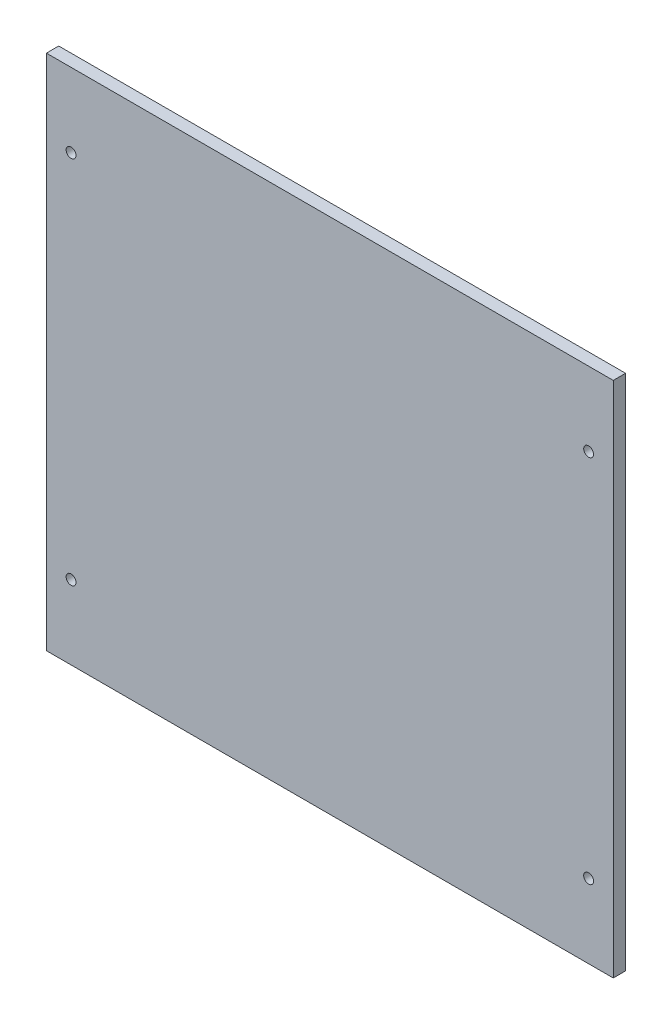
from build123d import *

# Parameters (mm, degrees)
SKETCH1_W           = 230
SKETCH1_H           = 210
BOSS_EXTRUDE1_DEPTH = 5
SKETCH2_R           = 2
CUT_EXTRUDE1_DEPTH  = 25


with BuildPart() as part:
    # Sketch1 → Boss-Extrude1 (new body)
    with BuildSketch(Plane.XY):
        Rectangle(SKETCH1_W, SKETCH1_H)
    extrude(amount=BOSS_EXTRUDE1_DEPTH)

    # Sketch2 → Cut-Extrude1 (cut)
    with BuildSketch(Plane.XY.offset(5)):
        with Locations((-105, 75)):
            Circle(SKETCH2_R)
        with Locations((-105, -75)):
            Circle(SKETCH2_R)
        with Locations((105, -75)):
            Circle(SKETCH2_R)
        with Locations((105, 75)):
            Circle(SKETCH2_R)
    extrude(amount=-CUT_EXTRUDE1_DEPTH, mode=Mode.SUBTRACT)


solid = part.part
